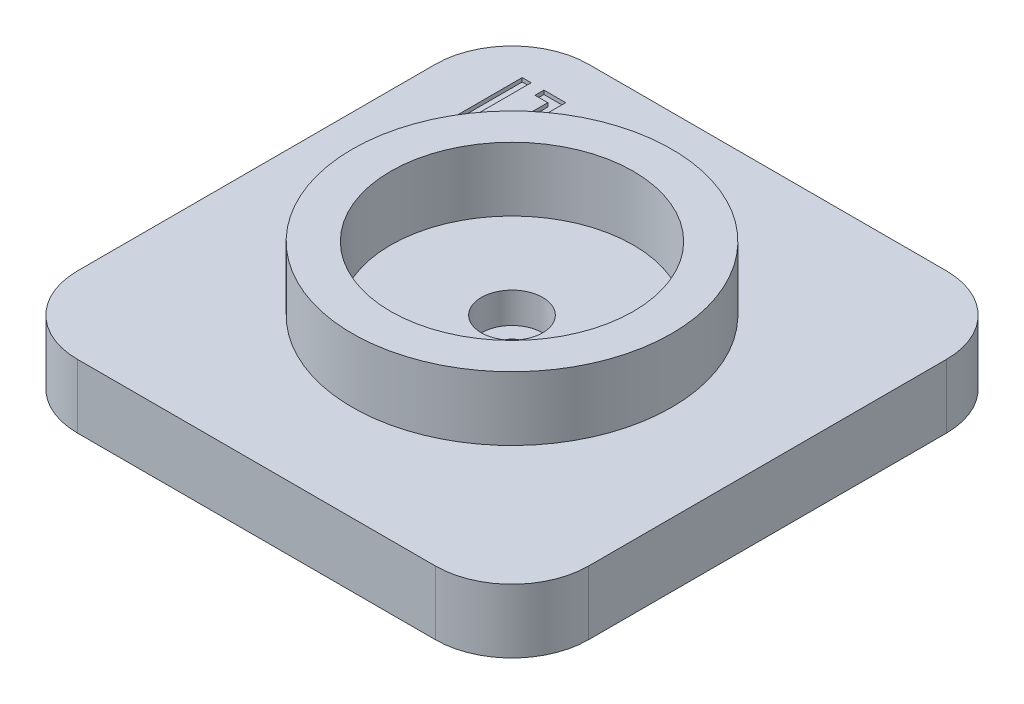
from build123d import *

# Parameters (mm, degrees)
SALIENTE_EXTRUIR1_DEPTH      = 4
SALIENTE_EXTRUIR1_DEPTH_BACK = 1
CROQUIS4_R                   = 6
CORTAR_EXTRUIR1_DEPTH        = 1.5
CROQUIS8_R                   = 2.4
CORTAR_EXTRUIR2_DEPTH        = 2.4
CORTAR_EXTRUIR3_REACH        = 4.6
CROQUIS9_R                   = 1.1
CROQUIS10_R                  = 12.5
CROQUIS10_R_2                = 9.5
EXTRUIR_L_MINA1_DEPTH        = 5
CORTAR_EXTRUIR4_DEPTH        = 0.3


with BuildPart() as part:
    # Croquis1 → Saliente-Extruir1 (new body, two sides)
    with BuildSketch(Plane(origin=(0, 0, 0), x_dir=(1, 0, 0), z_dir=(0, 1, 0))) as saliente_extruir1_sk:
        with BuildLine():
            Line((-14, 20), (14, 20))
            ThreePointArc((14, 20), (18.242640687, 18.242640687), (20, 14))
            Line((20, 14), (20, -14))
            ThreePointArc((20, -14), (18.242640687, -18.242640687), (14, -20))
            Line((14, -20), (-14, -20))
            ThreePointArc((-14, -20), (-18.242640687, -18.242640687), (-20, -14))
            Line((-20, -14), (-20, 14))
            ThreePointArc((-20, 14), (-18.242640687, 18.242640687), (-14, 20))
        make_face()
    extrude(amount=SALIENTE_EXTRUIR1_DEPTH)
    extrude(saliente_extruir1_sk.sketch, amount=-SALIENTE_EXTRUIR1_DEPTH_BACK)

    # Croquis4 → Cortar-Extruir1 (cut)
    with BuildSketch(Plane.XZ.offset(1)):
        Circle(CROQUIS4_R)
    extrude(amount=-CORTAR_EXTRUIR1_DEPTH, mode=Mode.SUBTRACT)

    # Croquis8 → Cortar-Extruir2 (cut)
    with BuildSketch(Plane(origin=(0, 4, 0), x_dir=(1, 0, 0), z_dir=(0, 1, 0))):
        Circle(CROQUIS8_R)
    extrude(amount=-CORTAR_EXTRUIR2_DEPTH, mode=Mode.SUBTRACT)

    # Croquis9 → Cortar-Extruir3 (cut, up to next)
    with BuildSketch(Plane(origin=(0, 1.6, 0), x_dir=(1, 0, 0), z_dir=(0, 1, 0)), mode=Mode.PRIVATE) as cortar_extruir3_sk1:
        Circle(CROQUIS9_R)
    cortar_extruir3_tool1 = extrude(cortar_extruir3_sk1.sketch, amount=-CORTAR_EXTRUIR3_REACH, mode=Mode.PRIVATE) & part.part
    add(cortar_extruir3_tool1.solids().sort_by_distance((0, 1.6, 0))[0], mode=Mode.SUBTRACT)

    # Croquis10 → Extruir-Lámina1 (add)
    with BuildSketch(Plane(origin=(0, 4, 0), x_dir=(1, 0, 0), z_dir=(0, 1, 0))):
        Circle(CROQUIS10_R)
        Circle(CROQUIS10_R_2, mode=Mode.SUBTRACT)
    extrude(amount=EXTRUIR_L_MINA1_DEPTH)

    # Croquis11 → Cortar-Extruir4 (cut)
    with BuildSketch(Plane(origin=(0, 4, 0), x_dir=(1, 0, 0), z_dir=(0, 1, 0))):
        Polygon((-14, 11.5), (-14, 12.2), (-15, 12.2), (-15, 16.5), (-15.7, 16.5), (-15.7, 11.5), align=None)
        Polygon((-12.3, 16.5), (-14, 16.5), (-14, 15.8), (-13, 15.8), (-13, 11.5), (-12.3, 11.5), align=None)
    extrude(amount=-CORTAR_EXTRUIR4_DEPTH, mode=Mode.SUBTRACT)


solid = part.part
